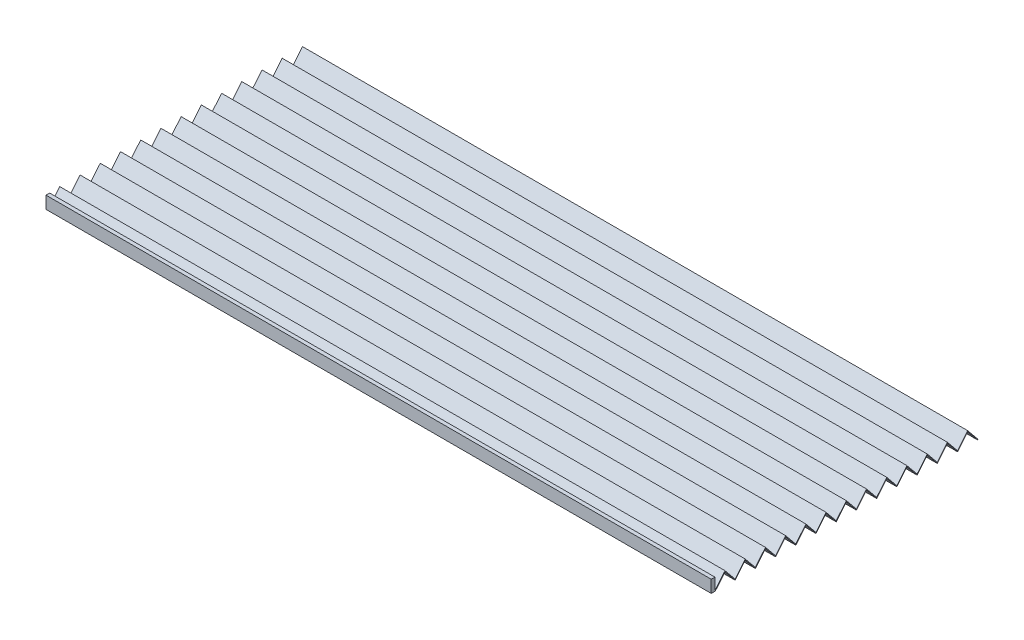
from build123d import *

# Parameters (mm, degrees)
SKETCH2_W           = 540
SKETCH2_H           = 10
BOSS_EXTRUDE1_DEPTH = 3
EXTRUDE_THIN1_DEPTH = 540


with BuildPart() as part:
    # Sketch2 → Boss-Extrude1 (new body)
    with BuildSketch(Plane.XY):
        with Locations((0, 5)):
            Rectangle(SKETCH2_W, SKETCH2_H)
    extrude(amount=BOSS_EXTRUDE1_DEPTH)

    # Sketch3 → Extrude-Thin1 (add, through all)
    with BuildSketch(Plane(origin=(270, 0, 0), x_dir=(0, 0, -1), z_dir=(1, 0, 0))):
        Polygon((0.193258825, -0.158590751), (8.206132428, 9.605903879), (16.412264855, -0.394096121), (24.618397283, 9.605903879), (32.824529711, -0.394096121), (41.030662139, 9.605903879), (49.236794566, -0.394096121), (57.442926994, 9.605903879), (65.649059422, -0.394096121), (73.85519185, 9.605903879), (82.061324277, -0.394096121), (90.267456705, 9.605903879), (98.473589133, -0.394096121), (106.679721561, 9.605903879), (114.885853988, -0.394096121), (123.091986416, 9.605903879), (131.298118844, -0.394096121), (139.504251272, 9.605903879), (147.710383699, -0.394096121), (155.916516127, 9.605903879), (164.122648555, -0.394096121), (172.328780983, 9.605903879), (180.53491341, -0.394096121), (188.741045838, 9.605903879), (196.947178266, -0.394096121), (205.153310694, 9.605903879), (213.166184296, -0.158590751), (213.552701947, 0.158590751), (205.153310694, 10.394096121), (196.947178266, 0.394096121), (188.741045838, 10.394096121), (180.53491341, 0.394096121), (172.328780983, 10.394096121), (164.122648555, 0.394096121), (155.916516127, 10.394096121), (147.710383699, 0.394096121), (139.504251272, 10.394096121), (131.298118844, 0.394096121), (123.091986416, 10.394096121), (114.885853988, 0.394096121), (106.679721561, 10.394096121), (98.473589133, 0.394096121), (90.267456705, 10.394096121), (82.061324277, 0.394096121), (73.85519185, 10.394096121), (65.649059422, 0.394096121), (57.442926994, 10.394096121), (49.236794566, 0.394096121), (41.030662139, 10.394096121), (32.824529711, 0.394096121), (24.618397283, 10.394096121), (16.412264855, 0.394096121), (8.206132428, 10.394096121), (-0.193258825, 0.158590751), align=None)
    extrude(amount=-EXTRUDE_THIN1_DEPTH)


solid = part.part
